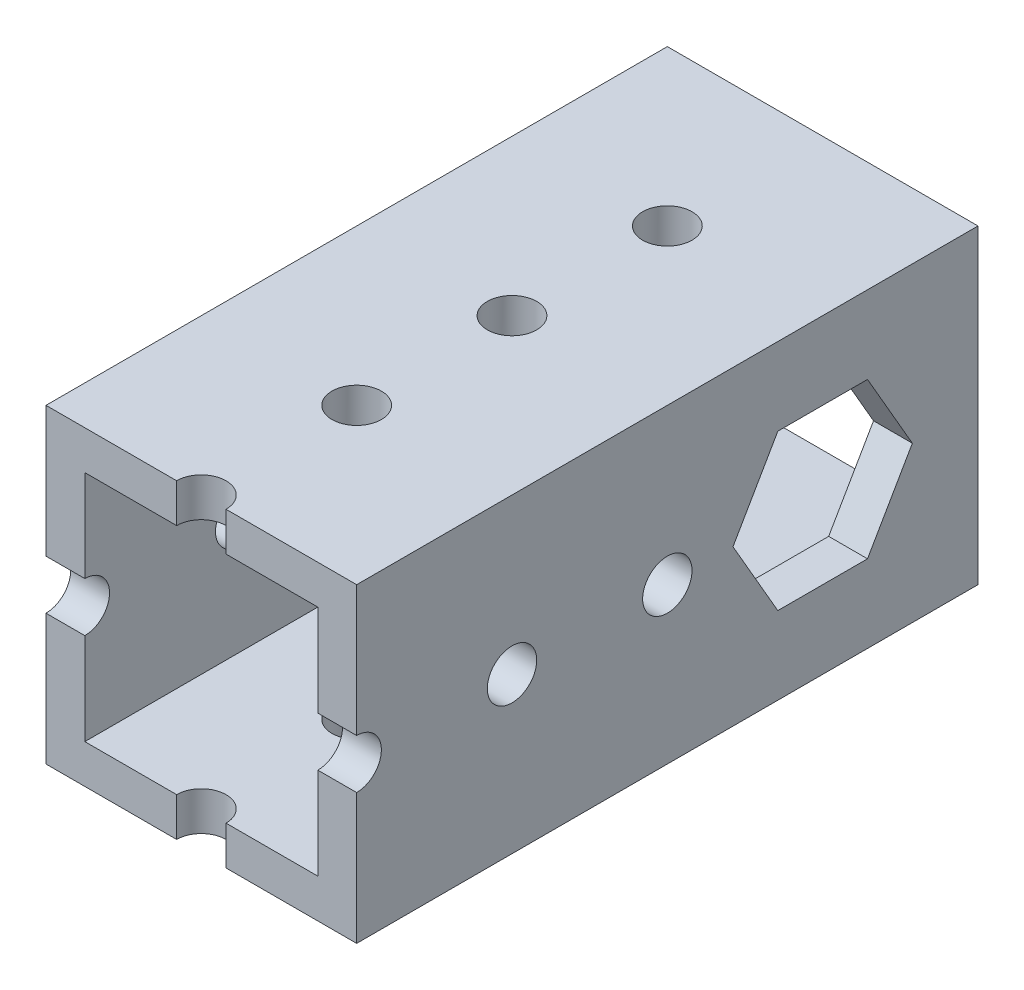
from build123d import *

# Parameters (mm, degrees)
SKETCH1_W           = 25.4
SKETCH1_H           = 25.4
SKETCH1_W_2         = 19.05
SKETCH1_H_2         = 19.05
BOSS_EXTRUDE1_DEPTH = 63.5
SKETCH2_R           = 2.0193
CUT_EXTRUDE1_DEPTH  = 63.5
SKETCH3_R           = 2.0193
CUT_EXTRUDE2_DEPTH  = 63.5
CUT_EXTRUDE3_DEPTH  = 28.702
SKETCH5_W           = 25.4
SKETCH5_H           = 25.4
CUT_EXTRUDE4_DEPTH  = 12.7


with BuildPart() as part:
    # Sketch1 → Boss-Extrude1 (new body)
    with BuildSketch(Plane.XY):
        with Locations((12.7, 12.7)):
            Rectangle(SKETCH1_W, SKETCH1_H)
        with Locations((12.7, 12.7)):
            Rectangle(SKETCH1_W_2, SKETCH1_H_2, mode=Mode.SUBTRACT)
    extrude(amount=BOSS_EXTRUDE1_DEPTH)

    # Sketch2 → Cut-Extrude1 (cut)
    with BuildSketch(Plane(origin=(0, 25.4, 0), x_dir=(1, 0, 0), z_dir=(0, 1, 0))):
        with Locations((12.7, -50.8)):
            Circle(SKETCH2_R)
        with Locations((12.7, -38.1)):
            Circle(SKETCH2_R)
        with Locations((12.7, -25.4)):
            Circle(SKETCH2_R)
        with Locations((12.7, -12.7)):
            Circle(SKETCH2_R)
    extrude(amount=-CUT_EXTRUDE1_DEPTH, mode=Mode.SUBTRACT)

    # Sketch3 → Cut-Extrude2 (cut)
    with BuildSketch(Plane(origin=(25.4, 0, 0), x_dir=(0, 0, -1), z_dir=(1, 0, 0))):
        with Locations((-50.8, 12.7)):
            Circle(SKETCH3_R)
        with Locations((-38.1, 12.7)):
            Circle(SKETCH3_R)
        with Locations((-25.4, 12.7)):
            Circle(SKETCH3_R)
        with Locations((-12.7, 12.7)):
            Circle(SKETCH3_R)
    extrude(amount=-CUT_EXTRUDE2_DEPTH, mode=Mode.SUBTRACT)

    # Sketch4 → Cut-Extrude3 (cut)
    with BuildSketch(Plane(origin=(25.4, 0, 0), x_dir=(0, 0, -1), z_dir=(1, 0, 0))):
        Polygon((-9.033825791, 19.05), (-16.366174209, 19.05), (-20.032348419, 12.7), (-16.366174209, 6.35), (-9.033825791, 6.35), (-5.367651581, 12.7), align=None)
    extrude(amount=-CUT_EXTRUDE3_DEPTH, mode=Mode.SUBTRACT)

    # Sketch5 → Cut-Extrude4 (cut)
    with BuildSketch(Plane.XY.offset(63.5)):
        with Locations((12.7, 12.7)):
            Rectangle(SKETCH5_W, SKETCH5_H)
    extrude(amount=-CUT_EXTRUDE4_DEPTH, mode=Mode.SUBTRACT)


solid = part.part
